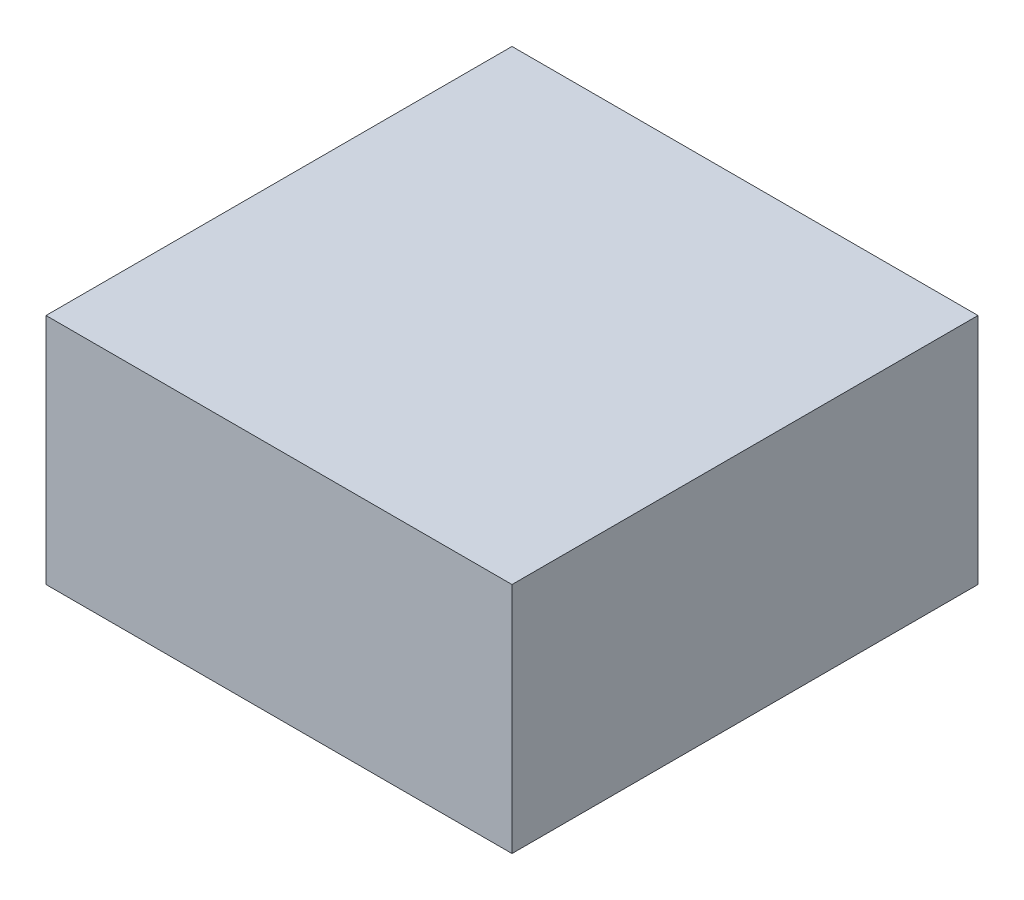
from build123d import *

# Parameters (mm, degrees)
SKETCH1_W           = 20
SKETCH1_H           = 10
BOSS_EXTRUDE1_DEPTH = 20
SKETCH2_R           = 0.5
SLICE_2_DEPTH       = 0.3


with BuildPart() as part:
    # Sketch1 → Boss-Extrude1 (new body)
    with BuildSketch(Plane.XY):
        Rectangle(SKETCH1_W, SKETCH1_H)
    extrude(amount=BOSS_EXTRUDE1_DEPTH)


with BuildPart() as body_2:
    # ag/agcl electrodes: sweep along a path in Sketch3
    with BuildLine(Plane(origin=(7.5, 0, 0), x_dir=(0, 0, -1), z_dir=(1, 0, 0))) as ag_agcl_electrodes_path:
        Line((-20, 4), (-5, 4))
        ThreePointArc((-5, 4), (-4.292893219, 4.292893219), (-4, 5))
    # Sketch2 → ag/agcl electrodes (sweep)
    with BuildSketch(Plane.XY.offset(20)):
        with Locations((-7.5, 4)):
            Circle(SKETCH2_R)
        with Locations((7.5, 4)):
            Circle(SKETCH2_R)
    sweep(path=ag_agcl_electrodes_path.line)


with BuildPart() as body_3:
    # Sketch4 → slice 2 (new body)
    with BuildSketch(Plane(origin=(0, -5, 0), x_dir=(1, 0, 0), z_dir=(0, 1, 0))):
        with BuildLine():
            add(Edge.make_bspline(
                [(-1.329786825, -12.04709664), (-1.196342031, -11.939424685), (-0.824147777, -11.548957834), (0.251281573, -11.322574475), (1.372606671, -11.746573561), (2.652909809, -13.571837262), (0.780549472, -13.104467787), (-0.122057097, -13.506347246), (-0.994791107, -13.460960152), (-1.586432094, -13.116889112), (-2.086144249, -12.539169772), (-1.569499382, -12.240512354), (-1.329786825, -12.04709664)],
                knots=[0, 0, 0, 0, 0.049562645, 0.182817887, 0.303261475, 0.461561344, 0.613381106, 0.684437877, 0.79516613, 0.866564728, 0.910968514, 1, 1, 1, 1], degree=3))
        make_face()
    extrude(amount=SLICE_2_DEPTH)


solid = Compound([part.part, body_2.part, body_3.part])
